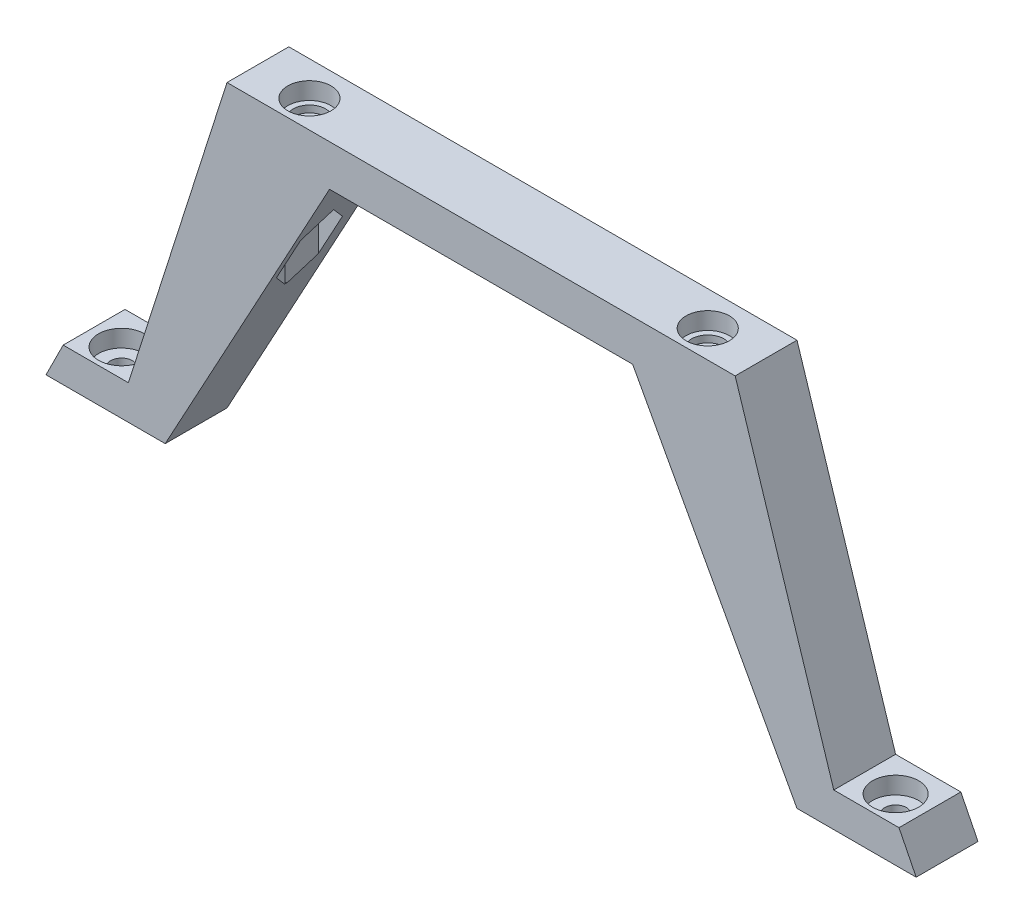
from build123d import *

# Parameters (mm, degrees)
EXTRUDE_1_DEPTH      = 10
SKETCH_7_R           = 1.55
CUT_EXTRUDE_1_DEPTH  = 47.544157215
CUT_EXTRUDE_2_DEPTH  = 18.5
SKETCH_19_W          = 126.714157214
SKETCH_19_H          = 0.99604336
CUT_EXTRUDE_14_DEPTH = 51.044157215
SKETCH_23_R          = 1.575
CUT_EXTRUDE_16_DEPTH = 10
SKETCH_24_R          = 3.35
CUT_EXTRUDE_17_DEPTH = 2.5


with BuildPart() as part:
    # 草图1 → 凸台-拉伸1 (new body)
    with BuildSketch(Plane.XY):
        Polygon((-3.188712924, 13.052848472), (33.811287076, 13.052848472), (33.811287076, 7.052848472), (15.60198174, 7.052848472), (11.74198174, 7.052848472), (-12.185815886, -36.991308743), (-14.185815886, -36.991308743), (-29.545791531, -36.991308743), (-27.045791531, -31.991308743), (-17.548712924, -31.991308743), align=None)
    extrude_1 = extrude(amount=EXTRUDE_1_DEPTH)

    # 镜向1: 凸台-拉伸1 across plane
    add(extrude_1.mirror(Plane(origin=(33.811287076, 13.052848472, 10), x_dir=(0, 0, 1), z_dir=(-1, 0, 0))))

    # 草图5 → 切除-旋转7 (revolve, cut)
    with BuildSketch(Plane.XY.offset(5)):
        Polygon((7.961287076, 13.052848472), (7.961287076, 10.552848472), (7.161287076, 10.552848472), (7.161287076, 9.552848472), (6.361287076, 9.552848472), (4.811287076, 9.552848472), (4.811287076, 13.052848472), align=None)
    cut_revolve_7 = revolve(axis=Axis((4.811287076, 9.552848472, 5), (0, 1, 0)), mode=Mode.SUBTRACT)

    # 草图7 → 切除-拉伸1 (cut, through all)
    with BuildSketch(Plane(origin=(0, 9.552848472, 0), x_dir=(1, 0, 0), z_dir=(0, 1, 0))):
        with Locations((4.811287076, -5)):
            Circle(SKETCH_7_R)
    cut_extrude_1 = extrude(amount=-CUT_EXTRUDE_1_DEPTH, mode=Mode.SUBTRACT)

    # 草图8 → 切除-拉伸2 (cut)
    with BuildSketch(Plane(origin=(0, -11.947151528, 0), x_dir=(1, 0, 0), z_dir=(0, 1, 0))):
        Polygon((8.333123718, -5), (6.572205397, -1.95), (3.050368755, -1.95), (1.289450434, -5), (3.050368755, -8.05), (6.572205397, -8.05), align=None)
    cut_extrude_2 = extrude(amount=CUT_EXTRUDE_2_DEPTH, mode=Mode.SUBTRACT)

    # 草图19 → 切除-拉伸14 (cut, through all)
    with BuildSketch(Plane(origin=(0, 13.052848472, 0), x_dir=(1, 0, 0), z_dir=(0, 1, 0))):
        with Locations((33.811287076, -9.50197832)):
            Rectangle(SKETCH_19_W, SKETCH_19_H)
    extrude(amount=-CUT_EXTRUDE_14_DEPTH, mode=Mode.SUBTRACT)

    # 草图23 → 切除-拉伸16 (cut)
    with BuildSketch(Plane(origin=(0, -31.991308743, 0), x_dir=(1, 0, 0), z_dir=(0, 1, 0))):
        with Locations((-22.548712924, -5)):
            Circle(SKETCH_23_R)
    cut_extrude_16 = extrude(amount=-CUT_EXTRUDE_16_DEPTH, mode=Mode.SUBTRACT)

    # 草图24 → 切除-拉伸17 (cut)
    with BuildSketch(Plane(origin=(0, -31.991308743, 0), x_dir=(1, 0, 0), z_dir=(0, 1, 0))):
        with Locations((-22.548712924, -5)):
            Circle(SKETCH_24_R)
    cut_extrude_17 = extrude(amount=-CUT_EXTRUDE_17_DEPTH, mode=Mode.SUBTRACT)

    # 镜向3: 切除-旋转7, 切除-拉伸1, 切除-拉伸2, 切除-拉伸16, 切除-拉伸17 across plane
    add(cut_revolve_7.mirror(Plane(origin=(33.811287076, 0, 0), x_dir=(0, 0, 1), z_dir=(1, 0, 0))), mode=Mode.SUBTRACT)
    add(cut_extrude_1.mirror(Plane(origin=(33.811287076, 0, 0), x_dir=(0, 0, 1), z_dir=(1, 0, 0))), mode=Mode.SUBTRACT)
    add(cut_extrude_2.mirror(Plane(origin=(33.811287076, 0, 0), x_dir=(0, 0, 1), z_dir=(1, 0, 0))), mode=Mode.SUBTRACT)
    add(cut_extrude_16.mirror(Plane(origin=(33.811287076, 0, 0), x_dir=(0, 0, 1), z_dir=(1, 0, 0))), mode=Mode.SUBTRACT)
    add(cut_extrude_17.mirror(Plane(origin=(33.811287076, 0, 0), x_dir=(0, 0, 1), z_dir=(1, 0, 0))), mode=Mode.SUBTRACT)


solid = part.part
